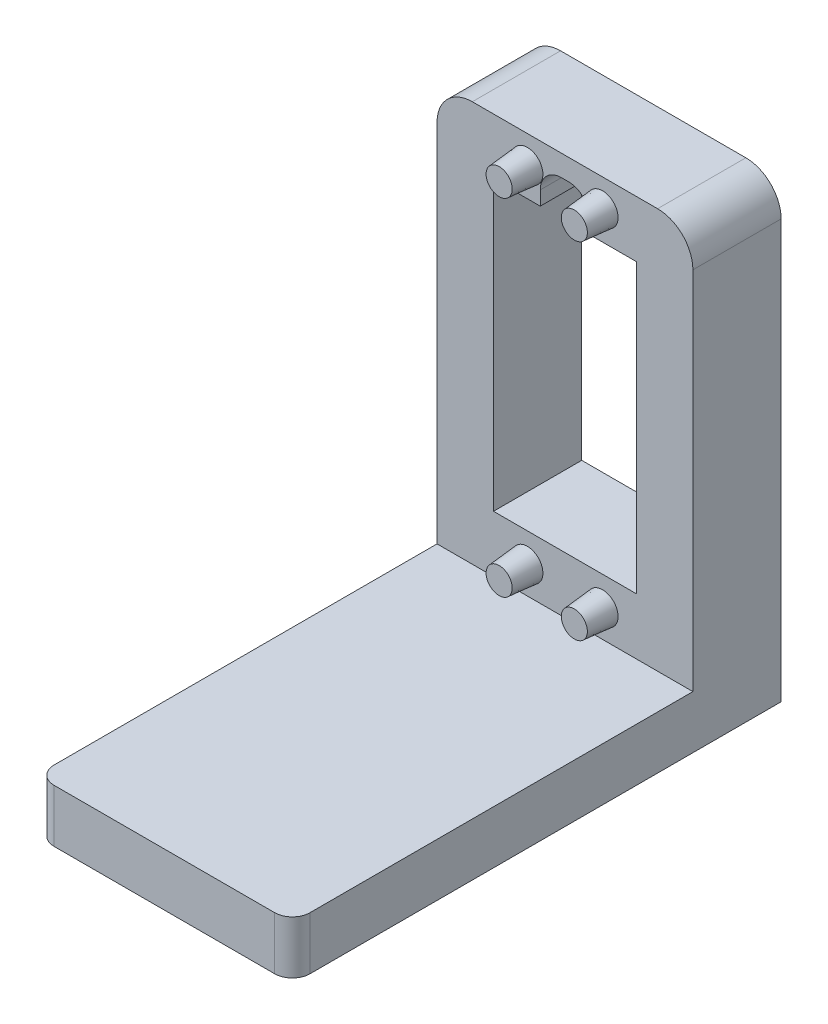
from build123d import *

# Parameters (mm, degrees)
SKETCH1_W                = 36.25
SKETCH1_H                = 56.75
SKETCH1_W_2              = 20.25
SKETCH1_H_2              = 40.75
BOSS_EXTRUDE1_DEPTH      = 12.5
SKETCH3_W                = 36.25
SKETCH3_H                = 7.5
BOSS_EXTRUDE2_DEPTH      = 56.75
BOSS_EXTRUDE2_DEPTH_BACK = 12.5
CUT_EXTRUDE1_DEPTH       = 13.5
SKETCH5_R                = 2.2
BOSS_EXTRUDE3_DEPTH      = 4
BOSS_EXTRUDE3_TAPER      = 5
FILLET1_R                = 5
FILLET2_R                = 2.5


with BuildPart() as part:
    # Sketch1 → Boss-Extrude1 (new body)
    with BuildSketch(Plane.XY):
        with Locations((10.125, 20.375)):
            Rectangle(SKETCH1_W, SKETCH1_H)
        with Locations((10.125, 20.375)):
            Rectangle(SKETCH1_W_2, SKETCH1_H_2, mode=Mode.SUBTRACT)
    extrude(amount=BOSS_EXTRUDE1_DEPTH)

    # Sketch3 → Boss-Extrude2 (add, two sides)
    with BuildSketch(Plane.XY.offset(12.5)) as boss_extrude2_sk:
        with Locations((10.125, -11.75)):
            Rectangle(SKETCH3_W, SKETCH3_H)
    extrude(amount=BOSS_EXTRUDE2_DEPTH)
    extrude(boss_extrude2_sk.sketch, amount=-BOSS_EXTRUDE2_DEPTH_BACK)

    # Sketch4 → Cut-Extrude1 (cut, through all)
    with BuildSketch(Plane.XY.offset(12.5)):
        with BuildLine():
            Line((6.625, 40.75), (13.625, 40.75))
            Line((13.625, 40.75), (13.625, 42.75))
            ThreePointArc((13.625, 42.75), (12.746320344, 44.871320344), (10.625, 45.75))
            Line((10.625, 45.75), (9.625, 45.75))
            ThreePointArc((9.625, 45.75), (7.503679656, 44.871320344), (6.625, 42.75))
            Line((6.625, 42.75), (6.625, 40.75))
        make_face()
    extrude(amount=-CUT_EXTRUDE1_DEPTH, mode=Mode.SUBTRACT)

    # Sketch5 → Boss-Extrude3 (add)
    with BuildSketch(Plane.XY.offset(12.5)):
        with Locations((4.8, 44.85)):
            Circle(SKETCH5_R)
        with Locations((15.45, 44.85)):
            Circle(SKETCH5_R)
        with Locations((15.45, -4.1)):
            Circle(SKETCH5_R)
        with Locations((4.8, -4.1)):
            Circle(SKETCH5_R)
    extrude(amount=BOSS_EXTRUDE3_DEPTH, taper=BOSS_EXTRUDE3_TAPER)

    # Fillet1
    fillet1_edges = [part.edges().sort_by_distance(p)[0] for p in [
        (-8, 48.75, 6.25),
        (28.25, 48.75, 6.25),
    ]]
    fillet(fillet1_edges, radius=FILLET1_R)

    # Fillet2
    fillet2_edges = [part.edges().sort_by_distance(p)[0] for p in [
        (-8, -11.75, 69.25),
        (28.25, -11.75, 69.25),
    ]]
    fillet(fillet2_edges, radius=FILLET2_R)


solid = part.part
